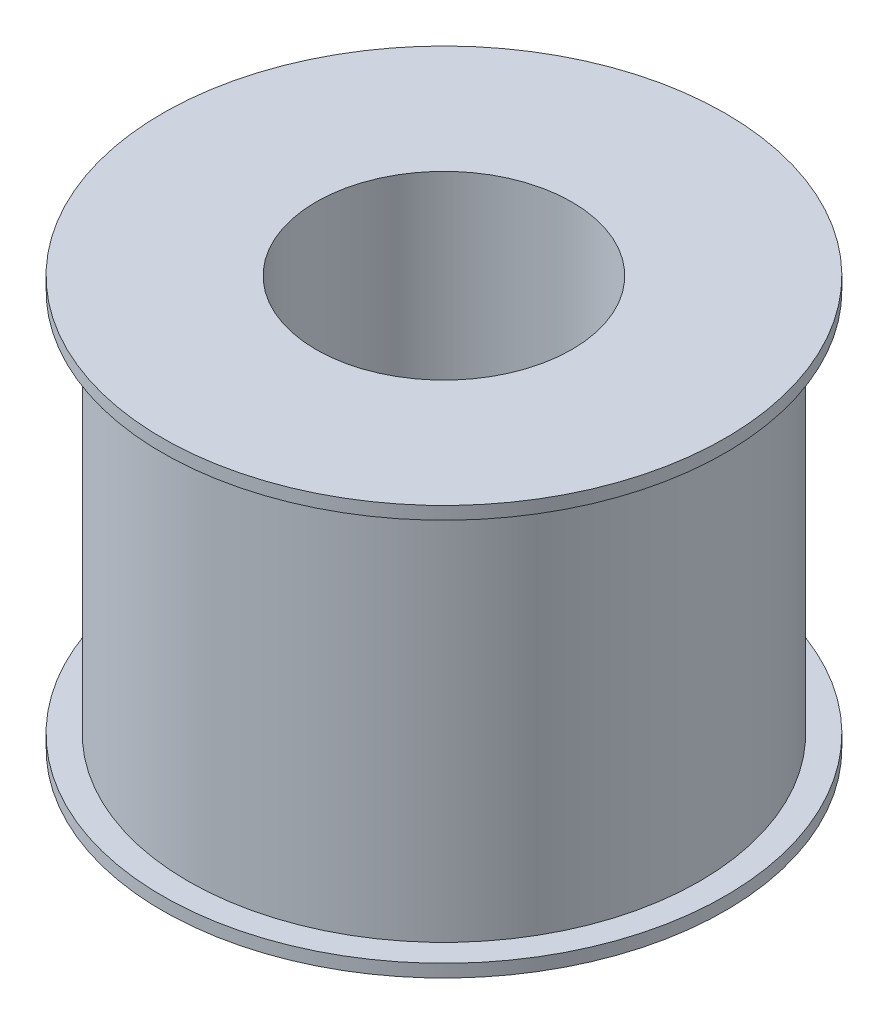
from build123d import *


with BuildPart() as part:
    # Sketch1 → Revolve1 (revolve)
    with BuildSketch(Plane.XY):
        Polygon((5, 16.544117647), (11, 16.544117647), (11, 16.044117647), (10, 16.044117647), (10, 1.044117647), (11, 1.044117647), (11, 0.544117647), (5, 0.544117647), align=None)
    revolve(axis=Axis((0, 0, 0), (0, 1, 0)))


solid = part.part
